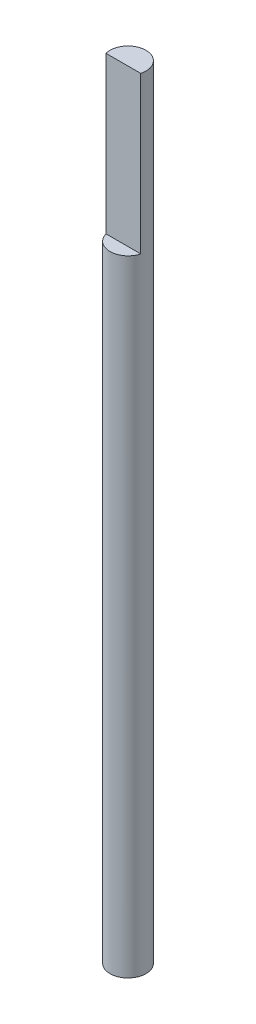
from build123d import *

# Parameters (mm, degrees)
SKETCH1_R           = 2.921
BOSS_EXTRUDE1_DEPTH = 127
SKETCH2_W           = 5.68457404
SKETCH2_H           = 2.372266765
CUT_EXTRUDE1_DEPTH  = 25.4


with BuildPart() as part:
    # Sketch1 → Boss-Extrude1 (new body)
    with BuildSketch(Plane(origin=(0, 0, 0), x_dir=(1, 0, 0), z_dir=(0, 1, 0))):
        Circle(SKETCH1_R)
    extrude(amount=BOSS_EXTRUDE1_DEPTH)

    # Sketch2 → Cut-Extrude1 (cut)
    with BuildSketch(Plane(origin=(0, 127, 0), x_dir=(1, 0, 0), z_dir=(0, 1, 0))):
        with Locations((0.020302225, -1.940217474)):
            Rectangle(SKETCH2_W, SKETCH2_H)
    extrude(amount=-CUT_EXTRUDE1_DEPTH, mode=Mode.SUBTRACT)


solid = part.part
